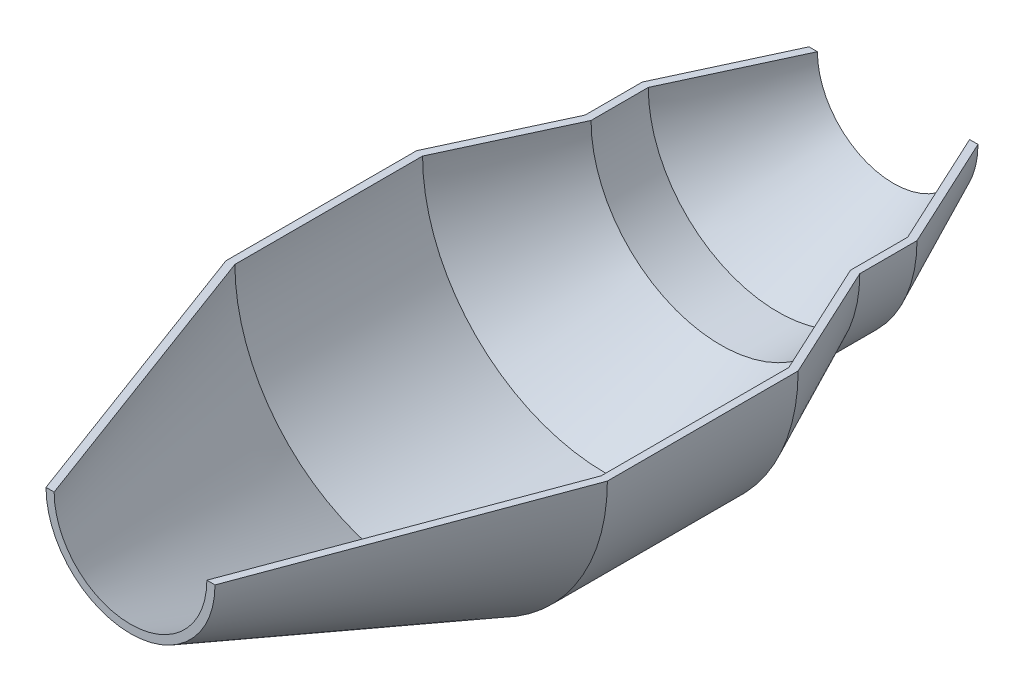
from build123d import *

# Parameters (mm, degrees)
REVOLVE1_ANGLE = 180


with BuildPart() as part:
    # Sketch3 → Revolve1 (revolve, symmetric)
    with BuildSketch(Plane(origin=(0, 0, 0), x_dir=(0, 0, -1), z_dir=(1, 0, 0))) as revolve1_sk:
        Polygon((-100, -22.15), (-25, -50), (25, -50), (55.161579892, -36), (70.161579892, -36), (100, -22.15), (100, -19.945050391), (69.720036749, -34), (54.720036749, -34), (24.558456857, -48), (-24.640654181, -48), (-100, -20.016562919), align=None)
    revolve(axis=Axis((0, 0, 100), (0, 0, -1)), revolution_arc=REVOLVE1_ANGLE / 2)
    revolve(revolve1_sk.sketch, axis=Axis((0, 0, 100), (0, 0, 1)), revolution_arc=REVOLVE1_ANGLE / 2)


solid = part.part
